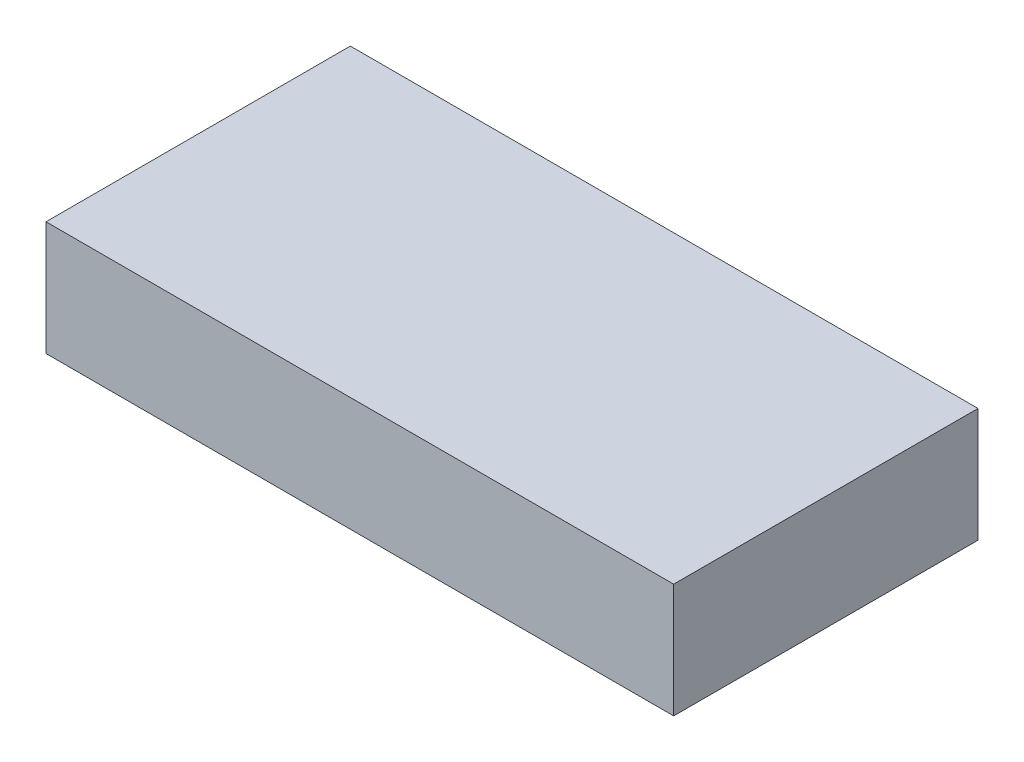
from build123d import *

# Parameters (mm, degrees)
SKETCH1_W           = 33
SKETCH1_H           = 16
BOSS_EXTRUDE1_DEPTH = 6


with BuildPart() as part:
    # Sketch1 → Boss-Extrude1 (new body)
    with BuildSketch(Plane(origin=(0, 0, 0), x_dir=(1, 0, 0), z_dir=(0, 1, 0))):
        Rectangle(SKETCH1_W, SKETCH1_H)
    extrude(amount=BOSS_EXTRUDE1_DEPTH)


solid = part.part
